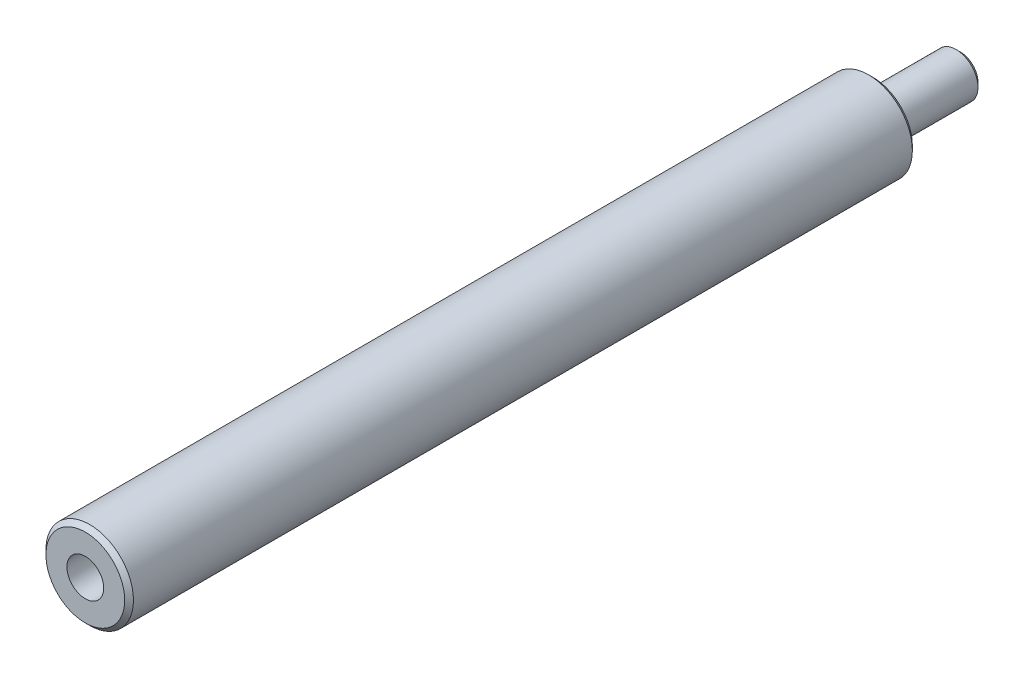
from build123d import *

# Parameters (mm, degrees)
ESQUISSE1_R                                   = 5
BOSS_EXTRU_1_DEPTH                            = 90
ESQUISSE2_R                                   = 2.5
BOSS_EXTRU_2_DEPTH                            = 10
TROU_POUR_TARAUDAGE_POUR_TROU_TARAUD_M5_D     = 4.2
TROU_POUR_TARAUDAGE_POUR_TROU_TARAUD_M5_DEPTH = 10
TROU_POUR_TARAUDAGE_POUR_TROU_TARAUD_M5_TIP   = 1.2618073
CHANFREIN1_SIZE                               = 0.5


with BuildPart() as part:
    # Esquisse1 → Boss.-Extru.1 (new body)
    with BuildSketch(Plane.XY):
        Circle(ESQUISSE1_R)
    extrude(amount=BOSS_EXTRU_1_DEPTH)

    # Esquisse2 → Boss.-Extru.2 (add)
    with BuildSketch(Plane(origin=(0, 0, 0), x_dir=(-1, 0, 0), z_dir=(0, 0, -1))):
        Circle(ESQUISSE2_R)
    extrude(amount=BOSS_EXTRU_2_DEPTH)

    # Trou pour taraudage pour trou taraudé M51
    with Locations(Plane.XY.offset(90)):
        with Locations((0, 0)):
            Hole(TROU_POUR_TARAUDAGE_POUR_TROU_TARAUD_M5_D / 2, depth=TROU_POUR_TARAUDAGE_POUR_TROU_TARAUD_M5_DEPTH)
            with Locations((0, 0, -(TROU_POUR_TARAUDAGE_POUR_TROU_TARAUD_M5_DEPTH + TROU_POUR_TARAUDAGE_POUR_TROU_TARAUD_M5_TIP / 2))):  # 118° drill point
                Cone(0, TROU_POUR_TARAUDAGE_POUR_TROU_TARAUD_M5_D / 2, TROU_POUR_TARAUDAGE_POUR_TROU_TARAUD_M5_TIP, mode=Mode.SUBTRACT)

    # Chanfrein1
    chanfrein1_edges = [part.edges().sort_by_distance(p)[0] for p in [
        (-5, 0, 0),
        (-5, 0, 90),
        (2.5, 0, -10),
    ]]
    chamfer(chanfrein1_edges, length=CHANFREIN1_SIZE)


solid = part.part
